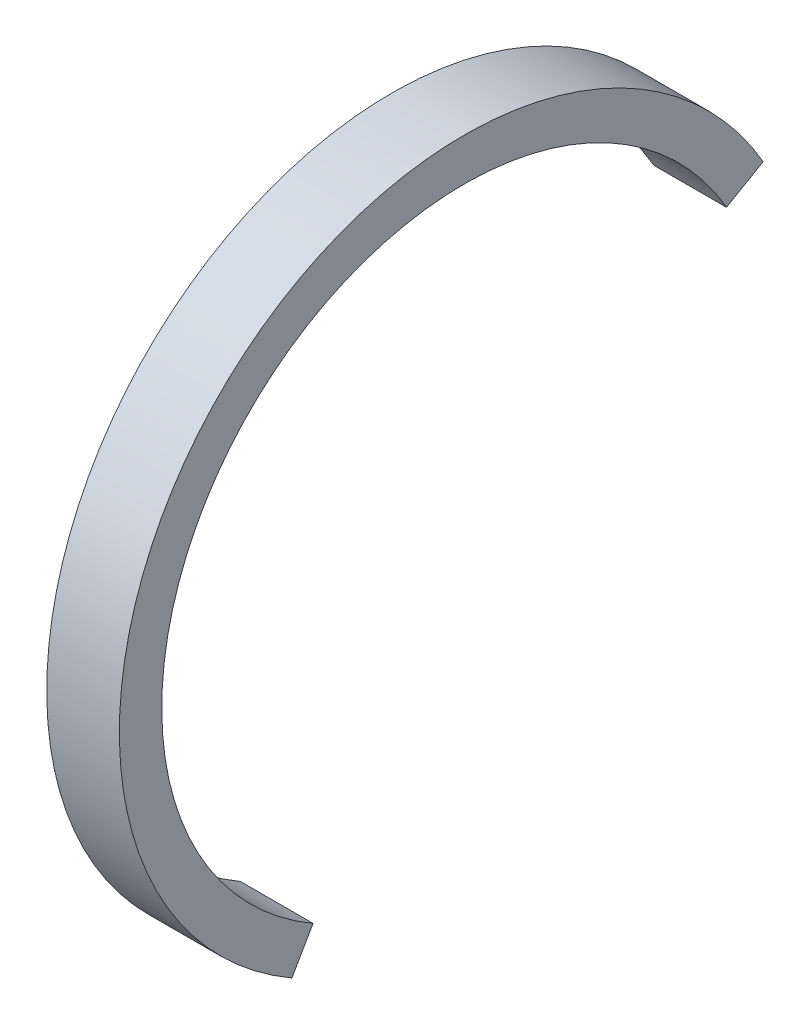
from build123d import *

# Parameters (mm, degrees)
BOSS_EXTRUDE1_DEPTH = 6


with BuildPart() as part:
    # Sketch1 → Boss-Extrude1 (new body)
    with BuildSketch(Plane(origin=(0, 0, 0), x_dir=(0, 0, -1), z_dir=(1, 0, 0))):
        with BuildLine():
            Line((-12.5, -21.650635095), (-14.25, -24.681724008))
            ThreePointArc((-14.25, -24.681724008), (-20.152543264, 20.152543264), (24.681724008, 14.25))
            Line((24.681724008, 14.25), (21.650635095, 12.5))
            ThreePointArc((21.650635095, 12.5), (-17.67766953, 17.67766953), (-12.5, -21.650635095))
        make_face()
    extrude(amount=BOSS_EXTRUDE1_DEPTH)


solid = part.part
